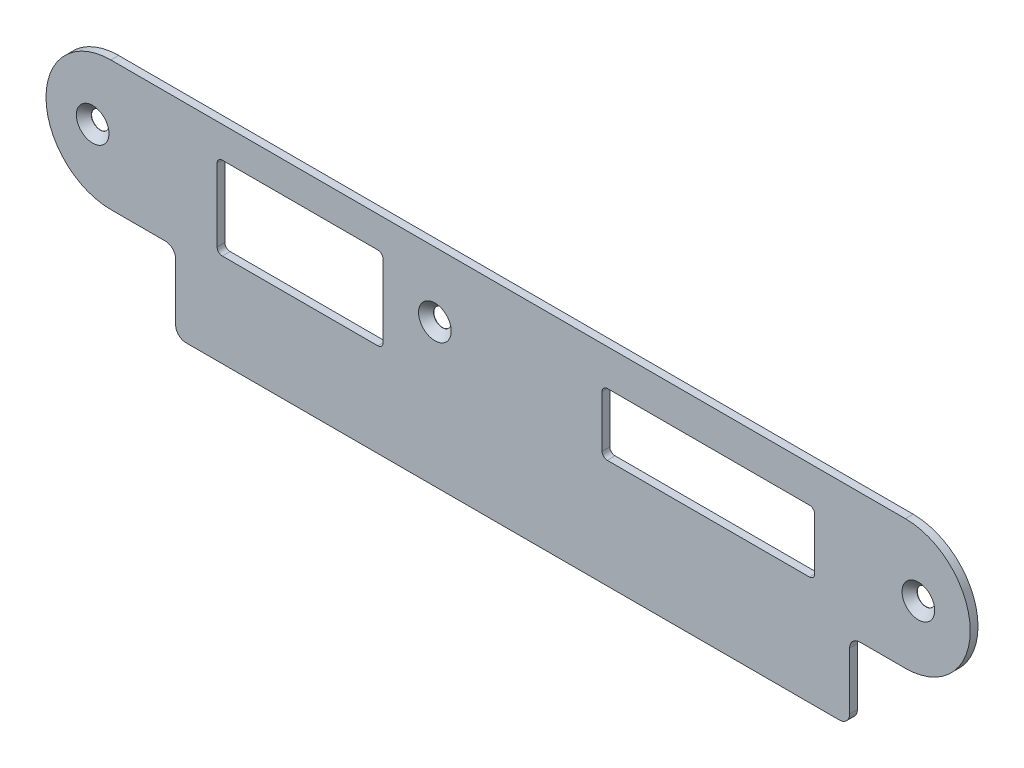
from build123d import *

# Parameters (mm, degrees)
ESQUISSE1_R                                 = 1
EXTRUSION1_DEPTH                            = 1.5
FRAISAGE_POUR_VIS_T_TE_FRAIS_E_M31_AT_COUNT = 2
FRAISAGE_POUR_VIS_T_TE_FRAIS_E_M31_AT_PITCH = 66
FRAISAGE_POUR_VIS_T_TE_FRAIS_E_M31_2_COUNT  = 2
FRAISAGE_POUR_VIS_T_TE_FRAIS_E_M31_2_PITCH  = 159.25


with BuildPart() as part:
    # Esquisse1 → Extrusion1 (new body)
    with BuildSketch(Plane.XY):
        with BuildLine():
            Line((-83, -6), (-72.5, -6))
            ThreePointArc((-72.5, -6), (-71.085786438, -6.585786438), (-70.5, -8))
            Line((-70.5, -8), (-70.5, -19))
            ThreePointArc((-70.5, -19), (-69.914213562, -20.414213562), (-68.5, -21))
            Line((-68.5, -21), (57.5, -21))
            ThreePointArc((57.5, -21), (58.914213562, -20.414213562), (59.5, -19))
            Line((59.5, -19), (59.5, -8))
            ThreePointArc((59.5, -8), (60.085786438, -6.585786438), (61.5, -6))
            Line((61.5, -6), (70.25, -6))
            ThreePointArc((70.25, -6), (82.75, 6.5), (70.25, 19))
            Line((70.25, 19), (-83, 19))
            ThreePointArc((-83, 19), (-95.5, 6.5), (-83, -6))
        make_face()
        with Locations((-86.5, 6.5)):
            Circle(ESQUISSE1_R, mode=Mode.SUBTRACT)
        with Locations((-20.5, 6.5)):
            Circle(ESQUISSE1_R, mode=Mode.SUBTRACT)
        with Locations((72.75, 6.5)):
            Circle(ESQUISSE1_R, mode=Mode.SUBTRACT)
        with BuildLine():
            Line((-31.5, 13), (-61.5, 13))
            ThreePointArc((-61.5, 13), (-62.207106781, 12.707106781), (-62.5, 12))
            Line((-62.5, 12), (-62.5, -2))
            ThreePointArc((-62.5, -2), (-62.207106781, -2.707106781), (-61.5, -3))
            Line((-61.5, -3), (-31.5, -3))
            ThreePointArc((-31.5, -3), (-30.792893219, -2.707106781), (-30.5, -2))
            Line((-30.5, -2), (-30.5, 12))
            ThreePointArc((-30.5, 12), (-30.792893219, 12.707106781), (-31.5, 13))
        make_face(mode=Mode.SUBTRACT)
        with BuildLine():
            Line((51.75, 12), (12.75, 12))
            ThreePointArc((12.75, 12), (12.042893219, 11.707106781), (11.75, 11))
            Line((11.75, 11), (11.75, 1))
            ThreePointArc((11.75, 1), (12.042893219, 0.292893219), (12.75, 0))
            Line((12.75, 0), (51.75, 0))
            ThreePointArc((51.75, 0), (52.457106781, 0.292893219), (52.75, 1))
            Line((52.75, 1), (52.75, 11))
            ThreePointArc((52.75, 11), (52.457106781, 11.707106781), (51.75, 12))
        make_face(mode=Mode.SUBTRACT)
    extrude(amount=EXTRUSION1_DEPTH)

    # Esquisse2 → Fraisage pour vis à tête fraisée M31 (revolve, cut)
    with BuildSketch(Plane(origin=(-86.5, 6.5, 1.5), x_dir=(0, -1, 0), z_dir=(1, 0, 0))):
        Polygon((0, 0), (0, 1.5), (1.7, 1.5), (1.7, 1.45), (3.15, 0), align=None)
    fraisage_pour_vis_t_te_frais_e_m31 = revolve(axis=Axis((-86.5, 6.5, 7.85), (0, 0, -1)), mode=Mode.SUBTRACT)

    # Fraisage pour vis à tête fraisée M31 at: Fraisage pour vis à tête fraisée M31 ×2
    with Locations(*[(i * FRAISAGE_POUR_VIS_T_TE_FRAIS_E_M31_AT_PITCH, 0, 0) for i in range(1, FRAISAGE_POUR_VIS_T_TE_FRAIS_E_M31_AT_COUNT)]):
        add(fraisage_pour_vis_t_te_frais_e_m31, mode=Mode.SUBTRACT)

    # Fraisage pour vis _ t_te frais_e M31 2: Fraisage pour vis à tête fraisée M31 ×2
    with Locations(*[(i * FRAISAGE_POUR_VIS_T_TE_FRAIS_E_M31_2_PITCH, 0, 0) for i in range(1, FRAISAGE_POUR_VIS_T_TE_FRAIS_E_M31_2_COUNT)]):
        add(fraisage_pour_vis_t_te_frais_e_m31, mode=Mode.SUBTRACT)


solid = part.part
